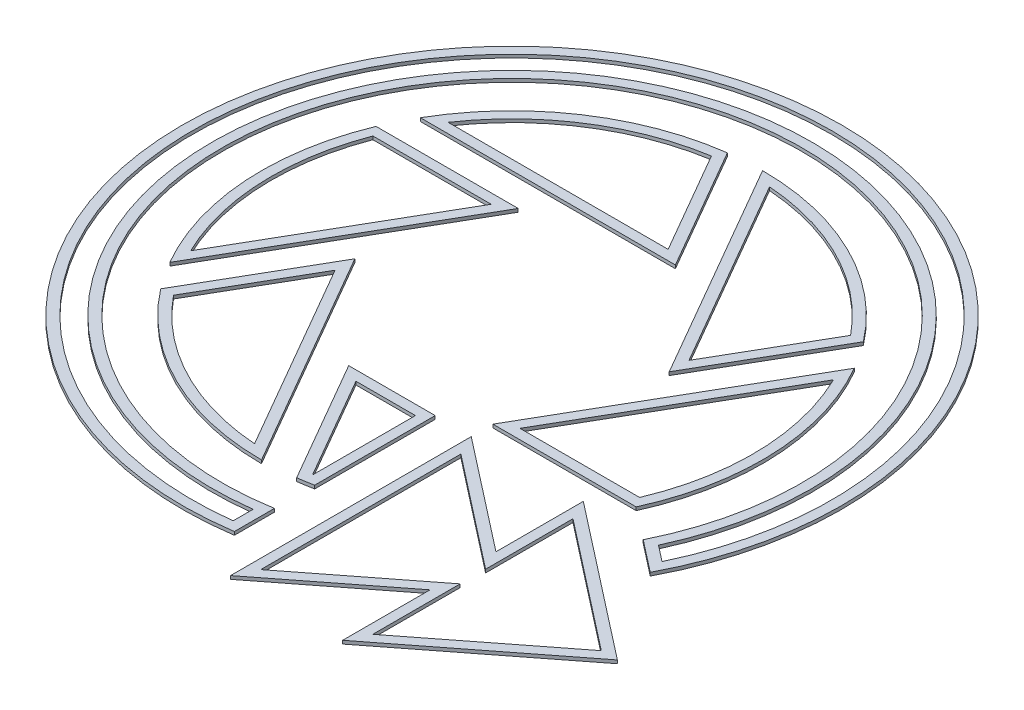
from build123d import *

# Parameters (mm, degrees)
EXTRUDE_1_DEPTH     = 5
EXTRUDE_1_2_DEPTH   = 5
EXTRUDE_1_3_DEPTH   = 5
EXTRUDE_1_4_DEPTH   = 5
EXTRUDE_1_5_DEPTH   = 5
EXTRUDE_1_6_DEPTH   = 5
EXTRUDE_1_7_DEPTH   = 5
EXTRUDE_1_8_DEPTH   = 5
CUT_EXTRUDE_1_DEPTH = 5


with BuildPart() as part:
    # 草图1 → 凸台-拉伸1 (new body)
    with BuildSketch(Plane(origin=(0, 0, 0), x_dir=(1, 0, 0), z_dir=(0, 1, 0))):
        with BuildLine():
            Line((-109.696551146, 190), (-329.089653438, 190))
            ThreePointArc((-329.089653438, 190), (-211.305466091, 315.832233947), (-50.050204348, 376.68949686))
            Line((-50.050204348, 376.68949686), (57.735026919, 190))
            Line((57.735026919, 190), (-109.696551146, 190))
        make_face()
    extrude(amount=EXTRUDE_1_DEPTH)


with BuildPart() as body_2:
    # 草图1 → Extrude 1 2 (new body)
    with BuildSketch(Plane(origin=(0, 0, 0), x_dir=(1, 0, 0), z_dir=(0, 1, 0))):
        with BuildLine():
            Line((128.449935554, -157.518185391), (219.393102292, 0))
            Line((219.393102292, 0), (329.089653438, 190))
            ThreePointArc((329.089653438, 190), (379.560665165, 18.267497356), (345.815010187, -157.518185391))
            Line((345.815010187, -157.518185391), (128.449935554, -157.518185391))
        make_face()
    extrude(amount=EXTRUDE_1_2_DEPTH)


with BuildPart() as body_3:
    # 草图1 → Extrude 1 3 (new body)
    with BuildSketch(Plane(origin=(0, 0, 0), x_dir=(1, 0, 0), z_dir=(0, 1, 0))):
        with BuildLine():
            Line((193.412340179, 45), (109.696551146, 190))
            Line((109.696551146, 190), (0, 380))
            ThreePointArc((0, 380), (167.866004887, 340.912018567), (301.197571446, 231.68949686))
            Line((301.197571446, 231.68949686), (193.412340179, 45))
        make_face()
    extrude(amount=EXTRUDE_1_3_DEPTH)


with BuildPart() as body_4:
    # 草图1 → Extrude 1 4 (new body)
    with BuildSketch(Plane(origin=(0, 0, 0), x_dir=(1, 0, 0), z_dir=(0, 1, 0))):
        with BuildLine():
            Line((-135.67731326, 145), (-219.393102292, 0))
            Line((-219.393102292, 0), (-329.089653438, -190))
            ThreePointArc((-329.089653438, -190), (-379.171470978, -25.07978462), (-351.247775794, 145))
            Line((-351.247775794, 145), (-135.67731326, 145))
        make_face()
    extrude(amount=EXTRUDE_1_4_DEPTH)


with BuildPart() as body_5:
    # 草图1 → Extrude 1 5 (new body)
    with BuildSketch(Plane(origin=(0, 0, 0), x_dir=(1, 0, 0), z_dir=(0, 1, 0))):
        with BuildLine():
            Line((-193.412340179, -45), (-109.696551146, -190))
            Line((-109.696551146, -190), (0, -380))
            ThreePointArc((0, -380), (-167.866004887, -340.912018567), (-301.197571446, -231.68949686))
            Line((-301.197571446, -231.68949686), (-193.412340179, -45))
        make_face()
    extrude(amount=EXTRUDE_1_5_DEPTH)


with BuildPart() as body_6:
    # 草图1 → Extrude 1 6 (new body)
    with BuildSketch(Plane(origin=(0, 0, 0), x_dir=(1, 0, 0), z_dir=(0, 1, 0))):
        with BuildLine():
            Line((-57.735026919, -190), (73.449935554, -190))
            Line((73.449935554, -190), (73.449935554, -372.83388656))
            ThreePointArc((73.449935554, -372.83388656), (61.780155161, -374.944279098), (50.050204348, -376.68949686))
            Line((50.050204348, -376.68949686), (-57.735026919, -190))
        make_face()
    extrude(amount=EXTRUDE_1_6_DEPTH)


with BuildPart() as body_7:
    # 草图1 → Extrude 1 7 (new body)
    with BuildSketch(Plane(origin=(0, 0, 0), x_dir=(1, 0, 0), z_dir=(0, 1, 0))):
        Polygon((128.449935554, -190.33388656), (128.449935554, -555.33388656), (298.449935554, -422.83388656), (298.449935554, -555.33388656), (532.60087895, -372.83388656), (298.449935554, -190.33388656), (298.449935554, -322.83388656), align=None)
    extrude(amount=EXTRUDE_1_7_DEPTH)


with BuildPart() as body_8:
    # 草图1 → Extrude 1 8 (new body)
    with BuildSketch(Plane(origin=(0, 0, 0), x_dir=(1, 0, 0), z_dir=(0, 1, 0))):
        with BuildLine():
            Line((73.449935554, -433.82612527), (73.449935554, -494.57568376))
            ThreePointArc((73.449935554, -494.57568376), (-289.254482056, 407.838012709), (442.470113798, -232.852310264))
            Line((442.470113798, -232.852310264), (394.283817369, -195.29534393))
            ThreePointArc((394.283817369, -195.29534393), (-262.522283469, 353.103456061), (73.449935554, -433.82612527))
        make_face()
    extrude(amount=EXTRUDE_1_8_DEPTH)


with BuildPart() as cut_extrude_1_tool:
    # 草图2 → 切除-拉伸1 (new body)
    with BuildSketch(Plane(origin=(0, 5, 0), x_dir=(1, 0, 0), z_dir=(0, 1, 0))):
        with BuildLine():
            Line((-161.658075373, 130), (-341.064510027, 130))
            ThreePointArc((-341.064510027, 130), (-364.657361136, -15.811671935), (-328.531896481, -159.033936612))
            Line((-328.531896481, -159.033936612), (-232.383483349, 7.5))
            Line((-232.383483349, 7.5), (-161.658075373, 130))
        make_face()
        with BuildLine():
            Line((58.449935554, -205), (-31.754264805, -205))
            Line((-31.754264805, -205), (57.948952522, -360.370530013))
            ThreePointArc((57.948952522, -360.370530013), (58.199458101, -360.330158434), (58.449935554, -360.28961272))
            Line((58.449935554, -360.28961272), (58.449935554, -205))
        make_face()
        with BuildLine():
            Line((-193.412340179, -75), (-283.115557506, -230.370530013))
            ThreePointArc((-283.115557506, -230.370530013), (-168.635370996, -323.708374388), (-26.53851907, -364.033936612))
            Line((-26.53851907, -364.033936612), (-122.686932203, -197.5))
            Line((-122.686932203, -197.5), (-193.412340179, -75))
        make_face()
        with BuildLine():
            Line((31.754264805, 205), (-57.948952522, 360.370530013))
            ThreePointArc((-57.948952522, 360.370530013), (-196.02199014, 307.896702453), (-301.993377411, 205))
            Line((-301.993377411, 205), (-109.696551146, 205))
            Line((-109.696551146, 205), (31.754264805, 205))
        make_face()
        with BuildLine():
            Line((122.686932203, 197.5), (193.412340179, 75))
            Line((193.412340179, 75), (283.115557506, 230.370530013))
            ThreePointArc((283.115557506, 230.370530013), (168.635370996, 323.708374388), (26.53851907, 364.033936612))
            Line((26.53851907, 364.033936612), (122.686932203, 197.5))
        make_face()
        with BuildLine():
            Line((328.531896481, 159.033936612), (232.383483349, -7.5))
            Line((232.383483349, -7.5), (154.430697668, -142.518185391))
            Line((154.430697668, -142.518185391), (336.026140103, -142.518185391))
            ThreePointArc((336.026140103, -142.518185391), (364.887334075, 9.068265075), (328.531896481, 159.033936612))
        make_face()
        with BuildLine():
            Line((58.449935554, -481.465061073), (58.449935554, -451.230102092))
            ThreePointArc((58.449935554, -451.230102092), (-269.289684738, 366.753412654), (413.023640021, -190.883401017))
            Line((413.023640021, -190.883401017), (437.279781879, -209.788923348))
            ThreePointArc((437.279781879, -209.788923348), (-282.646367638, 394.126922274), (58.449935554, -481.465061073))
        make_face()
        Polygon((313.449935554, -392.124728933), (313.449935554, -524.624728933), (508.200450297, -372.83388656), (313.449935554, -221.043044187), (313.449935554, -353.543044187), (143.449935554, -221.043044187), (143.449935554, -524.624728933), align=None)
    extrude(amount=-CUT_EXTRUDE_1_DEPTH)


with BuildPart() as part_1:
    add(part.part)

    # 切除-拉伸1: cut by cut_extrude_1_tool
    add(cut_extrude_1_tool.part, mode=Mode.SUBTRACT)


with BuildPart() as body_2_1:
    add(body_2.part)

    # 切除-拉伸1: cut by cut_extrude_1_tool
    add(cut_extrude_1_tool.part, mode=Mode.SUBTRACT)


with BuildPart() as body_3_1:
    add(body_3.part)

    # 切除-拉伸1: cut by cut_extrude_1_tool
    add(cut_extrude_1_tool.part, mode=Mode.SUBTRACT)


with BuildPart() as body_4_1:
    add(body_4.part)

    # 切除-拉伸1: cut by cut_extrude_1_tool
    add(cut_extrude_1_tool.part, mode=Mode.SUBTRACT)


with BuildPart() as body_5_1:
    add(body_5.part)

    # 切除-拉伸1: cut by cut_extrude_1_tool
    add(cut_extrude_1_tool.part, mode=Mode.SUBTRACT)


with BuildPart() as body_6_1:
    add(body_6.part)

    # 切除-拉伸1: cut by cut_extrude_1_tool
    add(cut_extrude_1_tool.part, mode=Mode.SUBTRACT)


with BuildPart() as body_7_1:
    add(body_7.part)

    # 切除-拉伸1: cut by cut_extrude_1_tool
    add(cut_extrude_1_tool.part, mode=Mode.SUBTRACT)


with BuildPart() as body_8_1:
    add(body_8.part)

    # 切除-拉伸1: cut by cut_extrude_1_tool
    add(cut_extrude_1_tool.part, mode=Mode.SUBTRACT)


solid = Compound([part_1.part, body_2_1.part, body_3_1.part, body_4_1.part, body_5_1.part, body_6_1.part, body_7_1.part, body_8_1.part])
